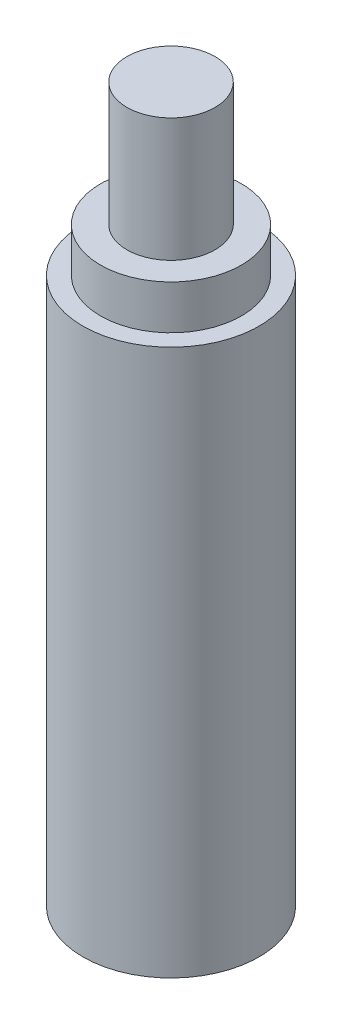
from build123d import *

# Parameters (mm, degrees)
ESQUISSE1_R        = 10
BOSS_EXTRU_1_DEPTH = 62
ESQUISSE2_R        = 8
BOSS_EXTRU_2_DEPTH = 5
ESQUISSE3_R        = 5
BOSS_EXTRU_3_DEPTH = 14


with BuildPart() as part:
    # Esquisse1 → Boss.-Extru.1 (new body)
    with BuildSketch(Plane(origin=(0, 0, 0), x_dir=(1, 0, 0), z_dir=(0, 1, 0))):
        with Locations(Location((0, 0, 0), (0, 0, 270))):  # turned: the seam where the file's is
            Circle(ESQUISSE1_R)
    extrude(amount=BOSS_EXTRU_1_DEPTH)

    # Esquisse2 → Boss.-Extru.2 (add)
    with BuildSketch(Plane(origin=(0, 62, 0), x_dir=(1, 0, 0), z_dir=(0, 1, 0))):
        with Locations(Location((0, 0, 0), (0, 0, 270))):  # turned: the seam where the file's is
            Circle(ESQUISSE2_R)
    extrude(amount=BOSS_EXTRU_2_DEPTH)

    # Esquisse3 → Boss.-Extru.3 (add)
    with BuildSketch(Plane(origin=(0, 67, 0), x_dir=(1, 0, 0), z_dir=(0, 1, 0))):
        with Locations(Location((0, 0, 0), (0, 0, 270))):  # turned: the seam where the file's is
            Circle(ESQUISSE3_R)
    extrude(amount=BOSS_EXTRU_3_DEPTH)


solid = part.part
